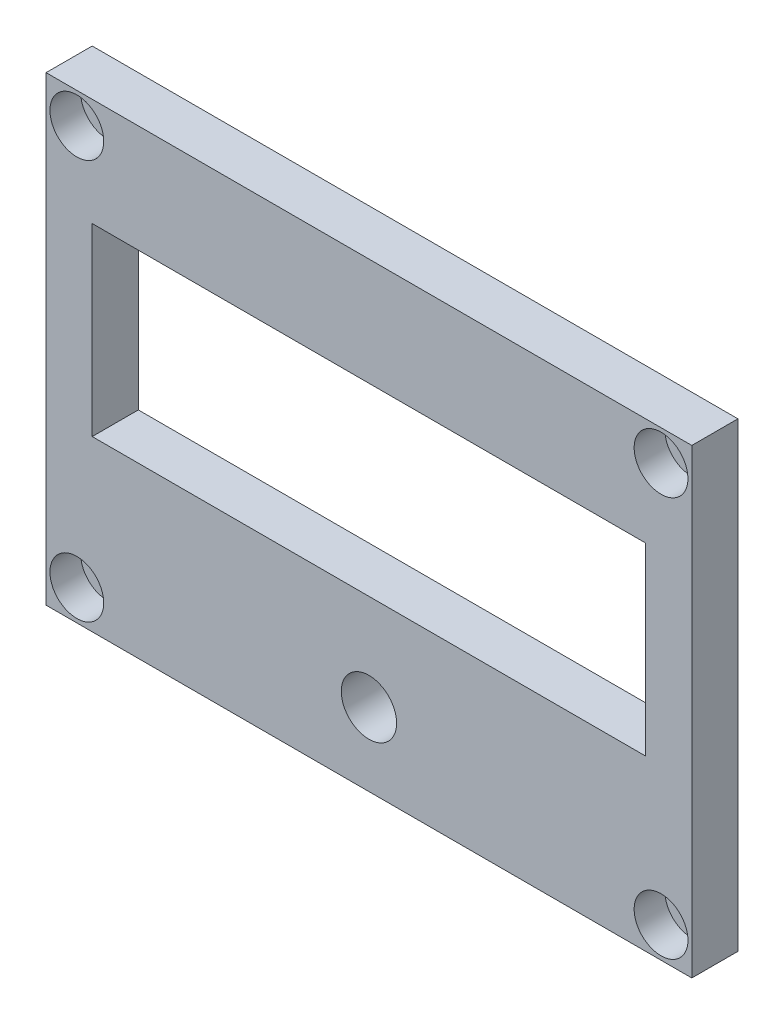
from build123d import *

# Parameters (mm, degrees)
BOSS_EXTRUDE1_DEPTH = 6
SKETCH3_R           = 3.5
CUT_EXTRUDE2_DEPTH  = 4
SKETCH4_R           = 2
CUT_EXTRUDE3_DEPTH  = 6
SKETCH6_R           = 3.6
CUT_EXTRUDE4_DEPTH  = 6
CUT_EXTRUDE6_START  = -6
SKETCH10_R          = 1.5
CUT_EXTRUDE6_DEPTH  = 4


with BuildPart() as part:
    # Sketch1 → Boss-Extrude1 (new body)
    with BuildSketch(Plane.XY):
        Polygon((-37, 30), (-40, 30), (-40, 27), (-40, -27), (-40, -30), (-37, -30), (37, -30), (44, -30), (44, -27), (44, 27), (44, 30), (37, 30), align=None)
    extrude(amount=BOSS_EXTRUDE1_DEPTH)

    # Sketch3 → Cut-Extrude2 (cut)
    with BuildSketch(Plane.XY.offset(6)):
        with Locations((-36, 26)):
            Circle(SKETCH3_R)
        with Locations((40, 26)):
            Circle(SKETCH3_R)
        with Locations((40, -26)):
            Circle(SKETCH3_R)
        with Locations((-36, -26)):
            Circle(SKETCH3_R)
    extrude(amount=-CUT_EXTRUDE2_DEPTH, mode=Mode.SUBTRACT)

    # Sketch4 → Cut-Extrude3 (cut)
    with BuildSketch(Plane.XY.offset(6)):
        with Locations((-36, 26)):
            Circle(SKETCH4_R)
        with Locations((40, 26)):
            Circle(SKETCH4_R)
        with Locations((40, -26)):
            Circle(SKETCH4_R)
        with Locations((-36, -26)):
            Circle(SKETCH4_R)
    extrude(amount=-CUT_EXTRUDE3_DEPTH, mode=Mode.SUBTRACT)

    # Sketch6 → Cut-Extrude4 (cut)
    with BuildSketch(Plane(origin=(0, 0, 0), x_dir=(-1, 0, 0), z_dir=(0, 0, -1))):
        with Locations((-2, -20.5)):
            Circle(SKETCH6_R)
        Polygon((30.5, -8), (-34.5, -8), (-38, -8), (-38, 16), (-2, 16), (34, 16), (34, -8), align=None)
    extrude(amount=-CUT_EXTRUDE4_DEPTH, mode=Mode.SUBTRACT)

    # Sketch10 → Cut-Extrude6 (cut)
    with BuildSketch(Plane.XY.offset(6).offset(CUT_EXTRUDE6_START)):
        with Locations((-36, 20)):
            Circle(SKETCH10_R)
        with Locations((40, 20)):
            Circle(SKETCH10_R)
        with Locations((40, -12)):
            Circle(SKETCH10_R)
        with Locations((-36, -12)):
            Circle(SKETCH10_R)
    extrude(amount=CUT_EXTRUDE6_DEPTH, mode=Mode.SUBTRACT)


solid = part.part
